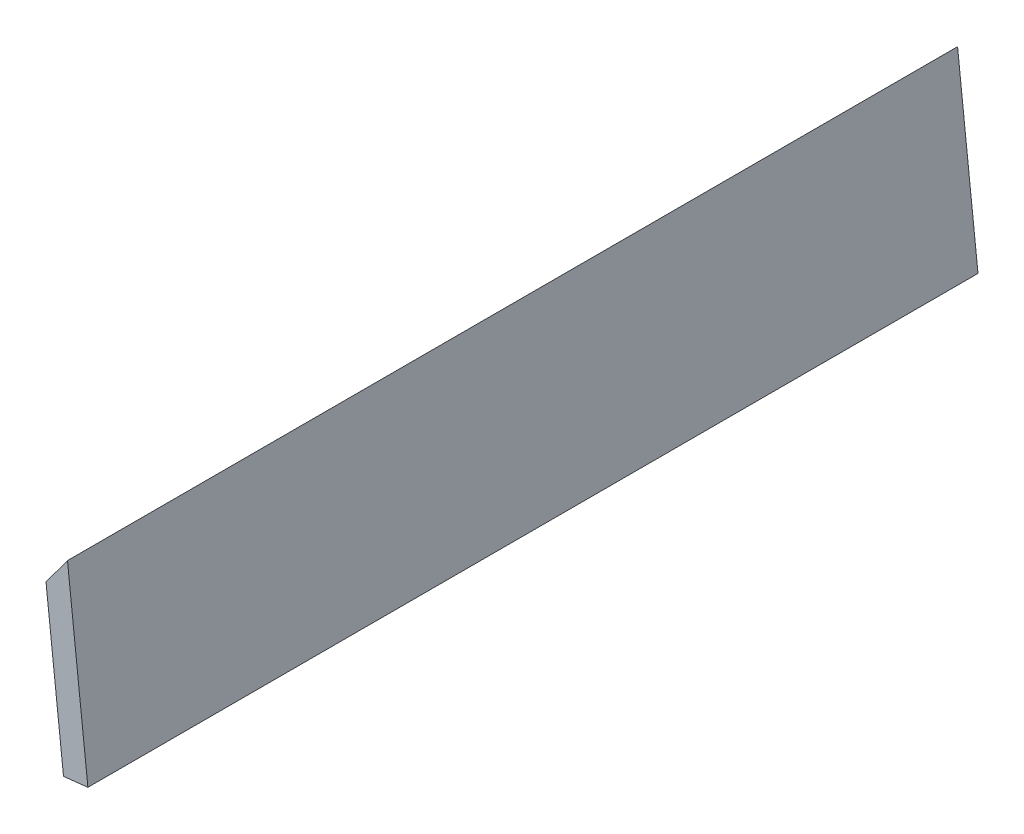
from build123d import *

# Parameters (mm, degrees)
BOSS_EXTRUDE1_DEPTH = 99.8


with BuildPart() as part:
    # Sketch1 → Boss-Extrude1 (new body)
    with BuildSketch(Plane.XY):
        Polygon((-17.200564762, -8.951549002), (-15.887883457, -7.161816492), (-14.793347919, -5.669507712), (-12.503593347, -26.544301699), (-15.237917986, -26.844229562), align=None)
    extrude(amount=BOSS_EXTRUDE1_DEPTH)


solid = part.part
